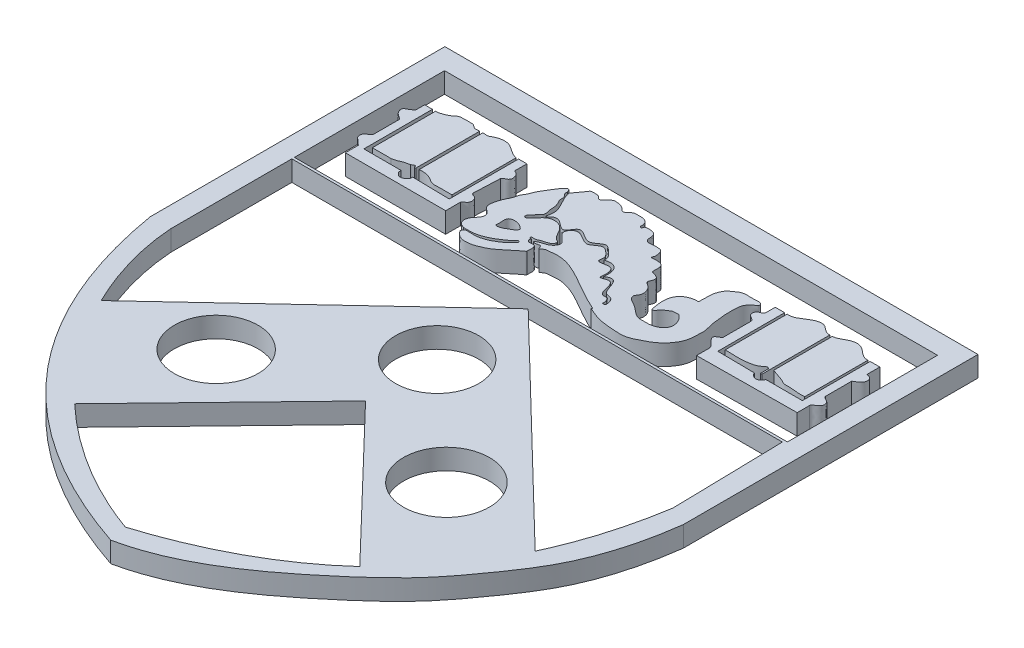
from build123d import *

# Parameters (mm, degrees)
SKETCH1_W           = 3061.588364983
SKETCH1_H           = 932.344777089
SKETCH1_R           = 260.223780603
SKETCH1_R_2         = 267.078180011
BOSS_EXTRUDE2_DEPTH = 127


with BuildPart() as part:
    # Sketch1 → Boss-Extrude2 (new body)
    with BuildSketch(Plane(origin=(0, 0, 0), x_dir=(1, 0, 0), z_dir=(0, 1, 0))):
        with BuildLine():
            add(Edge.make_bspline(
                [(4045.993063216, 2199.215225122), (4019.036003243, 1992.157900968), (3940.605770869, 1686.040008177), (3715.627358016, 1353.378287437), (3523.915777169, 1090.685545744), (3098.522374745, 703.752554607), (2693.684229103, 409.014184571), (2351.364587114, 337.566308676)],
                knots=[0, 0, 0, 0, 0.238562273, 0.347750957, 0.454000193, 0.606190934, 1, 1, 1, 1], degree=3))
            add(Edge.make_bspline(
                [(735.025873478, 2199.215225122), (970.843316792, 803.845705557), (2351.364587114, 337.566308676)],
                knots=[0, 0, 0, 1, 1, 1], degree=2))
            Line((735.025873478, 2199.215225122), (735.025873478, 4029.300547421))
            Line((735.025873478, 4029.300547421), (4045.993063216, 4029.300547421))
            Line((4045.993063216, 4029.300547421), (4045.993063216, 2199.215225122))
        make_face()
        with Locations((2394.042717303, 3432.829498618)):
            Rectangle(SKETCH1_W, SKETCH1_H, mode=Mode.SUBTRACT)
        with BuildLine():
            Line((3909.808358994, 2950.727967066), (3924.836899794, 2257.848334291))
            add(Edge.make_bspline(
                [(3924.836899794, 2257.848334291), (3711.113699994, 888.592759576), (2327.24082473, 452.829096435)],
                knots=[0, 0, 0, 1, 1, 1], degree=2))
            add(Edge.make_bspline(
                [(863.248534811, 2199.215225122), (877.47311589, 1989.403129671), (1118.77528022, 1216.127855732), (1775.94718937, 650.753368868), (2327.24082473, 452.829096435)],
                knots=[0, 0, 0, 0, 0.263514086, 1, 1, 1, 1], degree=3))
            Line((863.248534811, 2199.215225122), (863.248534811, 2950.727967066))
            Line((863.248534811, 2950.727967066), (3909.808358994, 2950.727967066))
        make_face(mode=Mode.SUBTRACT)
        with BuildLine():
            Line((2404.114497235, 2877.689743143), (1645.968612036, 2168.886509302))
            Line((1645.968612036, 2168.886509302), (2186.700620039, 2168.886509302))
            ThreePointArc((2186.700620039, 2168.886509302), (2313.474933953, 2567.530457451), (2652.412370001, 2322.356766959))
            ThreePointArc((2652.412370001, 2322.356766959), (2639.442955818, 2241.562435586), (2601.837910613, 2168.886509302))
            Line((2601.837910613, 2168.886509302), (3136.833426647, 2168.886509302))
            Line((3136.833426647, 2168.886509302), (2404.114497235, 2877.689743143))
        make_face()
        with BuildLine():
            Line((2186.700620039, 2168.886509302), (1645.968612036, 2168.886509302))
            Line((1645.968612036, 2168.886509302), (1033.524013592, 1596.301838725))
            add(Edge.make_bspline(
                [(1033.524013592, 1596.301838725), (1150.062361647, 1357.675014985), (1312.473356702, 1141.98075495), (1506.241949749, 958.912307426)],
                knots=[0.263514086, 0.263514086, 0.263514086, 0.263514086, 0.595636539, 0.595636539, 0.595636539, 0.595636539], degree=3))
            Line((1506.241949749, 958.912307426), (2394.269265326, 1877.454297427))
            Line((2394.269265326, 1877.454297427), (3267.142356524, 968.732165323))
            add(Edge.make_bspline(
                [(3728.737648851, 1596.301838725), (3559.118809212, 1233.711347288), (3267.142356524, 968.732165323)],
                knots=[0.265622113, 0.265622113, 0.265622113, 0.588988437, 0.588988437, 0.588988437], degree=2))
            Line((3728.737648851, 1596.301838725), (3136.833426647, 2168.886509302))
            Line((3136.833426647, 2168.886509302), (2601.837910613, 2168.886509302))
            ThreePointArc((2601.837910613, 2168.886509302), (2394.269265326, 2064.213662283), (2186.700620039, 2168.886509302))
        make_face()
        with Locations(Location((1653.259196935, 1690.93559152, 0), (0, 0, 270))):
            Circle(SKETCH1_R, mode=Mode.SUBTRACT)
        with Locations(Location((3083.04559979, 1690.93559152, 0), (0, 0, 270))):
            Circle(SKETCH1_R_2, mode=Mode.SUBTRACT)
        with BuildLine():
            add(Edge.make_bspline(
                [(2464.767037316, 3284.870494025), (2543.269819358, 3341.768334078), (2526.919244732, 3193.473978396), (2612.69470791, 3199.983108021), (2625.607421376, 3156.65465207), (2620.730937479, 3137.98419013)],
                knots=[0, 0, 0, 0, 0.586831291, 0.719707818, 1, 1, 1, 1], degree=3))
            Line((2620.730937479, 3137.98419013), (2603.084025454, 3137.98419013))
            add(Edge.make_bspline(
                [(2603.084025454, 3137.98419013), (2609.612915472, 3150.722889915), (2597.711627537, 3187.908577019), (2568.546530941, 3179.846963067), (2547.38089144, 3190.770216808), (2535.676967272, 3228.999651837), (2522.459617855, 3303.454171268), (2448.497240118, 3255.395384405), (2463.30640085, 3315.38994872), (2444.909493012, 3379.138282268), (2350.191254901, 3331.98123862), (2371.208442004, 3394.734318229), (2346.766229124, 3416.999233592), (2328.006165043, 3435.728370679), (2287.089575919, 3452.388606795), (2251.696858141, 3397.516196965), (2191.67790777, 3424.764262901), (2139.677802732, 3466.629554465), (2071.918788719, 3382.581092791), (2180.649082031, 3344.723562591), (2124.9486931, 3275.894794605), (2090.931864057, 3278.678610454), (2052.319167749, 3255.11213609), (2082.496059895, 3248.382490532), (2106.981578747, 3265.539443736), (2111.793633986, 3226.444059126), (2132.168593174, 3250.482111261), (2160.890726759, 3252.525076834), (2234.242378581, 3263.735226313), (2331.312183488, 3228.164699449), (2457.476715616, 3154.525364868), (2543.902080581, 3105.811460397), (2603.084025454, 3080.266973626)],
                knots=[0, 0, 0, 0, 0.032556061, 0.042948581, 0.052816971, 0.074630225, 0.120721843, 0.149452151, 0.169593618, 0.20705935, 0.251664852, 0.273960648, 0.296134008, 0.310450952, 0.325903722, 0.373059412, 0.395061266, 0.443790315, 0.47819684, 0.537519426, 0.563826413, 0.609542575, 0.616869593, 0.626603883, 0.647836981, 0.659655735, 0.672273917, 0.686951174, 0.717994813, 0.810907321, 0.876411443, 1, 1, 1, 1], degree=3))
            Line((2603.084025454, 3080.266973626), (2597.584863407, 3074.357913841))
            add(Edge.make_bspline(
                [(2597.584863407, 3074.357913841), (2608.974774561, 3069.30998213), (2640.046426606, 3055.873255387), (2696.027097611, 3036.672943159), (2772.670796603, 3029.996634607), (2847.16209479, 3023.308453093), (2900.977740862, 3046.786714057), (2929.248617867, 3062.480285098), (2968.754766282, 3081.123305601), (3026.625382521, 3124.356350293), (3068.67799265, 3196.784483692), (3068.994778868, 3264.835928169), (3074.355578085, 3310.562172072), (3058.175469267, 3353.800679368), (3053.642682679, 3393.48506246), (3049.536185981, 3426.151228403), (3047.176742493, 3452.814430142), (3045.42211855, 3477.270934381), (3046.249419033, 3498.95354119), (3047.065911211, 3526.077302814), (3047.695874264, 3554.619830796), (3064.38849516, 3580.725911522), (3082.573392728, 3599.530389383), (3104.498218826, 3606.22920432), (3103.097927236, 3626.464875974), (3080.65916707, 3635.768995416), (3054.661529994, 3629.29127928), (3019.449991823, 3631.251519654), (2991.275831749, 3631.903001573), (2964.713993883, 3620.634339325), (2946.882730267, 3605.947753608), (2922.300093096, 3590.971835009), (2908.920650715, 3565.965198211), (2898.426604665, 3539.288479415), (2896.719700125, 3514.955262525), (2896.163769466, 3485.394779706), (2893.629113567, 3466.229041479), (2896.746141536, 3442.596552121), (2881.966496535, 3445.855646122), (2867.913221451, 3444.031493119), (2847.545898595, 3439.266391985), (2825.52478124, 3429.843576895), (2801.438802673, 3411.474335417), (2782.612681095, 3377.027995909), (2777.901028676, 3327.657099719), (2784.537979988, 3294.556874466), (2790.536912617, 3247.567032361), (2812.921485506, 3270.268399927), (2822.99244638, 3284.915077594), (2839.142701291, 3297.482786031), (2851.632618396, 3304.568392773), (2864.418179087, 3313.802518999), (2881.071222263, 3313.723900775), (2903.314305468, 3317.480691503), (2918.608642284, 3301.386492021), (2940.386914172, 3274.192655642), (2954.33909077, 3219.551324075), (2894.999234337, 3167.976606658), (2837.828061905, 3169.140739084), (2784.699634964, 3170.633510758), (2748.91496638, 3198.292275263), (2710.938142866, 3231.684779821), (2670.031839253, 3246.73176231), (2663.113584001, 3263.851992945)],
                knots=[0.192850773, 0.192850773, 0.192850773, 0.192850773, 0.200326028, 0.213178327, 0.228039709, 0.246584143, 0.256741091, 0.262628514, 0.266030917, 0.282912316, 0.305525509, 0.312434736, 0.323658699, 0.332590135, 0.339619576, 0.347580918, 0.352343802, 0.355673279, 0.362282425, 0.365318683, 0.372005823, 0.379021887, 0.383081295, 0.388018719, 0.390335965, 0.39319185, 0.400958714, 0.406206298, 0.414340744, 0.417445142, 0.423283619, 0.428178801, 0.434404861, 0.439757248, 0.445316962, 0.448955812, 0.457208378, 0.458538805, 0.460712029, 0.463583766, 0.468045833, 0.472775597, 0.478007306, 0.485838641, 0.495786929, 0.505718817, 0.510762475, 0.514860474, 0.519077374, 0.522757832, 0.526657269, 0.527821209, 0.532088366, 0.53628665, 0.540515399, 0.544209276, 0.557818426, 0.568272004, 0.58612177, 0.590945066, 0.599687152, 0.61176102, 0.622578416, 0.622578416, 0.622578416, 0.622578416], degree=3))
            Line((2663.113584001, 3263.851992945), (2649.716964234, 3269.100201106))
            add(Edge.make_bspline(
                [(1929.963277011, 3569.644406702), (2365.286728969, 3792.7011874), (2649.716964234, 3269.100201106)],
                knots=[0, 0, 0, 1, 1, 1], degree=2))
            add(Edge.make_bspline(
                [(1929.963277011, 3569.644406702), (1952.014849921, 3528.268958704), (1979.300128061, 3488.381640917), (1959.428632751, 3434.367141661)],
                knots=[0.312671837, 0.312671837, 0.312671837, 0.312671837, 1, 1, 1, 1], degree=3))
            add(Edge.make_bspline(
                [(1959.428632751, 3434.367141661), (1967.259945647, 3426.67287531), (1980.261160084, 3448.879868834), (2030.59764576, 3463.628039217), (2090.429970884, 3373.674116364), (2135.512386846, 3508.376641384), (2228.700772585, 3384.524022341), (2294.545966584, 3482.656318698), (2350.932801628, 3429.531715851), (2382.353956214, 3404.951204328), (2376.728260476, 3376.260880501)],
                knots=[0, 0, 0, 0, 0.046896544, 0.113659028, 0.283898439, 0.409478672, 0.615730634, 0.76876615, 0.854488682, 1, 1, 1, 1], degree=3))
            add(Edge.make_bspline(
                [(2376.728260476, 3376.260880501), (2476.11541457, 3403.732739848), (2464.767037316, 3284.870494025)],
                knots=[0, 0, 0, 1, 1, 1], degree=2))
        make_face()
        with BuildLine():
            Line((2649.716964234, 3269.100201106), (2663.113584001, 3263.851992945))
            add(Edge.make_bspline(
                [(2663.113584001, 3263.851992945), (2661.314435892, 3268.304247084), (2659.437249368, 3278.337001283), (2669.467146029, 3289.603595943), (2678.438220618, 3306.94775862), (2679.993551581, 3331.89372017), (2667.460694632, 3359.288710159), (2649.386150598, 3376.901843711), (2630.680633081, 3386.391793642), (2628.102302849, 3401.757956908), (2637.963018996, 3416.083844994), (2641.079015906, 3441.473661656), (2620.630878092, 3453.025182425), (2606.804304375, 3458.793296074), (2589.997419032, 3459.323866855), (2587.851356068, 3484.752388195), (2592.370892236, 3505.383717874), (2582.151889227, 3526.432706376), (2565.962616412, 3535.85975865), (2544.534926688, 3536.713052368), (2528.02722003, 3538.339122119), (2505.81373652, 3533.921120885), (2518.188383093, 3557.15644223), (2512.634748374, 3572.652137825), (2511.325623212, 3592.887904674), (2498.575799957, 3607.652126226), (2474.678638199, 3609.705870773), (2447.432526563, 3610.577618027), (2418.128501654, 3603.668683746), (2398.972821668, 3622.499359043), (2401.731956085, 3645.406742795), (2393.351314984, 3673.979689604), (2365.337019011, 3682.387560051), (2344.158358739, 3682.794821411), (2321.97305899, 3679.962162555), (2323.807955354, 3662.352448063), (2310.92139946, 3664.770698828), (2308.228819505, 3673.951791703), (2309.686400777, 3683.972658839), (2306.493392336, 3697.306926911), (2298.598922716, 3711.993952013), (2283.245228429, 3719.133141224), (2266.969826322, 3723.72509874), (2248.585740392, 3721.919473017), (2230.853250535, 3722.987495794), (2215.081205031, 3721.417475261), (2204.316988095, 3713.34867902), (2194.355795639, 3706.462646602), (2185.95587467, 3694.705700891), (2167.584783872, 3693.577371457), (2156.716434401, 3708.515258083), (2142.511715712, 3718.493990965), (2125.320734422, 3725.671001327), (2106.792531652, 3725.433533612), (2089.062106511, 3729.158572588), (2075.678923082, 3718.310047357), (2059.772481578, 3707.858701922), (2050.636547518, 3687.558945865), (2029.140273862, 3685.341279051), (2022.092642363, 3699.762405994), (2007.02440534, 3706.513261807), (1990.544053456, 3706.088419403), (1976.750975108, 3706.881358423), (1965.0026361, 3705.008345715), (1957.205586106, 3694.639541928), (1949.152796939, 3680.877949586), (1932.780561207, 3661.896852963), (1921.604603977, 3643.807082717), (1913.046506608, 3631.810979489), (1909.573828675, 3629.344843141), (1908.050154284, 3628.504505843)],
                knots=[0.622578416, 0.622578416, 0.622578416, 0.622578416, 0.625391567, 0.628080948, 0.631118685, 0.637125295, 0.642228955, 0.648660331, 0.652411922, 0.653528867, 0.657540285, 0.662535819, 0.666454215, 0.670152397, 0.671995358, 0.67544046, 0.682233887, 0.685631317, 0.688460097, 0.693110559, 0.697807721, 0.700006392, 0.703062236, 0.708060927, 0.710804166, 0.714912606, 0.718382117, 0.724678312, 0.731927867, 0.734148812, 0.739638938, 0.744834377, 0.750590058, 0.755018119, 0.758916367, 0.760857028, 0.762734925, 0.764140702, 0.766243327, 0.768768016, 0.772249211, 0.775800013, 0.778528129, 0.782352131, 0.786682252, 0.789307634, 0.791554106, 0.794591531, 0.796578746, 0.799964401, 0.803593867, 0.807013434, 0.810397308, 0.814481912, 0.818257532, 0.820351551, 0.824402319, 0.829740311, 0.832472748, 0.835088191, 0.838358596, 0.841821403, 0.844874032, 0.846783204, 0.848544114, 0.852307293, 0.856483028, 0.863520807, 0.864774956, 0.865665049, 0.865665049, 0.865665049, 0.865665049], degree=3))
            add(Edge.make_bspline(
                [(1908.050154284, 3628.504505843), (1910.983429542, 3607.596499477), (1919.931815804, 3588.466474553), (1929.963277011, 3569.644406702)],
                knots=[0, 0, 0, 0, 0.312671837, 0.312671837, 0.312671837, 0.312671837], degree=3))
            add(Edge.make_bspline(
                [(1929.963277011, 3569.644406702), (2365.286728969, 3792.7011874), (2649.716964234, 3269.100201106)],
                knots=[0, 0, 0, 1, 1, 1], degree=2))
        make_face()
        with BuildLine():
            add(Edge.make_bspline(
                [(1773.99549811, 3084.398154876), (1775.594431531, 3081.748510418), (1783.880032077, 3070.091590704), (1799.078082721, 3056.07809208), (1831.663674296, 3042.349203232), (1860.093885791, 3044.878225576), (1890.039180943, 3050.267918379), (1911.650669491, 3058.608568849), (1984.00988121, 3087.281905523), (2032.290751031, 3142.419292102), (2087.975045788, 3179.913364778), (2090.429761997, 3184.399591279)],
                knots=[0.003789591, 0.003789591, 0.003789591, 0.003789591, 0.00565559, 0.012389798, 0.015797809, 0.026635126, 0.028667046, 0.03407684, 0.040466151, 0.075054585, 0.078282267, 0.078282267, 0.078282267, 0.078282267], degree=3))
            add(Edge.make_bspline(
                [(1898.554586681, 3627.001422707), (1889.38060856, 3608.103859064), (1917.597156624, 3598.037221519), (1916.091575637, 3574.957812313), (1915.291741954, 3563.222374466), (1921.457645796, 3548.558469769), (1934.500153236, 3527.412618002), (1938.851122963, 3504.586070504), (1937.8033998, 3484.644789518), (1940.756488942, 3473.030120682), (1945.763949514, 3458.769873184), (1944.487760084, 3445.249986555), (1944.556799684, 3433.913820276), (1938.42824419, 3428.739904377), (1931.783079285, 3423.475434565), (1924.005983131, 3414.236893144), (1917.458773938, 3400.088935471), (1904.629885016, 3390.060108128), (1895.13021172, 3379.349396666), (1892.219558835, 3362.08188531), (1909.213110383, 3359.505842189), (1918.624478497, 3369.33480997), (1931.636906007, 3380.139003226), (1944.148232564, 3396.487205793), (1960.150534772, 3415.00675922), (1980.621466748, 3431.104413238), (2009.791722559, 3435.807080141), (2039.692647368, 3432.135347274), (2070.436203583, 3411.325238565), (2091.102033199, 3376.089462704), (2108.111179598, 3342.126785488), (2138.700355972, 3329.812142341), (2134.991372681, 3311.075785802), (2122.492741531, 3298.389563815), (2102.687784377, 3291.003714794), (2072.539991473, 3285.733465754), (2053.318467334, 3268.713418963), (2024.666307547, 3278.484315629), (2027.770663536, 3260.825706355), (2040.985202279, 3266.247215705), (2030.683693003, 3251.53198696), (2045.072108074, 3234.733829245), (2064.7964562, 3241.628545398), (2086.74787946, 3238.307455002), (2092.844631378, 3212.289172135), (2089.204873459, 3196.485666127), (2090.429761997, 3184.399591279)],
                knots=[0, 0, 0, 0, 0.055654997, 0.063679332, 0.077751865, 0.095904148, 0.116878381, 0.163693439, 0.17230359, 0.185424146, 0.204637683, 0.223398045, 0.232509938, 0.241508714, 0.249140856, 0.262152688, 0.282474299, 0.302047336, 0.316579662, 0.333553046, 0.347506169, 0.361341168, 0.378962296, 0.406093804, 0.431577025, 0.463686413, 0.492891884, 0.530956126, 0.564787911, 0.61647831, 0.669611268, 0.694524273, 0.712220058, 0.723965263, 0.755621342, 0.782577775, 0.827890661, 0.84317039, 0.854771021, 0.863117951, 0.871846739, 0.893465526, 0.919753707, 0.939987678, 0.960256912, 1, 1, 1, 1], degree=3))
            add(Edge.make_bspline(
                [(1898.554586681, 3627.001422707), (1895.955798602, 3628.495439421), (1894.37010751, 3638.180993805), (1885.015130658, 3652.496177315), (1868.314593212, 3636.821636988), (1846.732987679, 3614.604807613), (1826.583227717, 3570.403211311), (1796.81015178, 3532.668764714), (1788.312005552, 3499.313273324), (1777.059999052, 3480.445625334), (1761.419152259, 3456.398928444), (1759.259406604, 3427.992356959), (1741.886942909, 3398.412020814), (1732.883711248, 3375.150847337), (1724.547819254, 3345.089345246), (1719.966646915, 3321.990483451), (1724.531174946, 3300.053616518), (1733.454961189, 3286.373767318), (1747.647912743, 3278.714196798), (1759.284953627, 3268.96954517), (1767.011999129, 3255.868931419), (1768.753746046, 3239.507040919), (1761.253363005, 3221.289896242), (1745.664990263, 3203.777486493), (1728.318570853, 3180.961799215), (1722.996628404, 3149.877011071), (1736.437514094, 3127.667125705), (1751.3611624, 3119.344193707), (1761.77567159, 3117.777428893), (1764.341643819, 3114.652068486)],
                knots=[0.867645066, 0.867645066, 0.867645066, 0.867645066, 0.869872345, 0.872557095, 0.875941044, 0.880285969, 0.892776985, 0.90362181, 0.908934181, 0.91310028, 0.916759684, 0.926012917, 0.929360397, 0.937236388, 0.940870006, 0.948141561, 0.950990265, 0.954137979, 0.957552212, 0.960531732, 0.963142666, 0.966489032, 0.969985937, 0.974607696, 0.980518496, 0.987045004, 0.992161658, 0.994749026, 0.997477608, 0.997477608, 0.997477608, 0.997477608], degree=3))
            add(Edge.make_bspline(
                [(1764.341643819, 3114.652068486), (1774.758651296, 3114.51244457), (1790.731801224, 3114.879596129), (1812.994629299, 3114.279713884), (1833.984673376, 3116.551854754), (1859.134072168, 3122.35036058), (1888.466167107, 3132.584040201), (1919.293954195, 3148.308288659), (1949.819529097, 3167.424240042), (1976.320888125, 3185.916065352), (1992.598304713, 3200.332723152), (1998.882706805, 3211.340564833), (2005.286254545, 3213.093208702), (2011.924775062, 3214.960309562), (2015.454004347, 3208.089777135), (2015.491784039, 3200.980165202), (2009.05052182, 3194.805363828), (2002.512853729, 3188.210025642), (1985.159029706, 3172.021771736), (1964.944967519, 3153.395532994), (1937.111715375, 3137.857815768), (1915.460023477, 3124.896199781), (1891.327149943, 3116.786241251), (1866.538873874, 3108.38103048), (1833.927469457, 3106.675833937), (1807.657835369, 3106.788492367), (1782.190044517, 3108.741136122), (1776.750426792, 3097.483926795), (1771.305366643, 3089.148719235), (1773.809968642, 3084.707650547)],
                knots=[0, 0, 0, 0, 0.054416946, 0.083521304, 0.116256377, 0.164416791, 0.218114949, 0.27818627, 0.344753145, 0.406484691, 0.446166985, 0.459403006, 0.468414198, 0.481036219, 0.488833912, 0.504336592, 0.514961118, 0.533716733, 0.553539365, 0.638661623, 0.676227808, 0.71984114, 0.770141158, 0.808714513, 0.856476611, 0.9368855, 0.958327214, 0.972460643, 0.999371445, 0.999371445, 0.999371445, 0.999371445], degree=3))
            add(Edge.make_bspline(
                [(1773.809968642, 3084.707650547), (1773.87150849, 3084.604301679), (1773.933353142, 3084.501137319), (1773.99549811, 3084.398154876)],
                knots=[0.003717066, 0.003717066, 0.003717066, 0.003717066, 0.003789591, 0.003789591, 0.003789591, 0.003789591], degree=3))
        make_face()
        with BuildLine():
            add(Edge.make_bspline(
                [(1852.354693182, 3230.474720809), (1855.883850773, 3221.919385108), (1884.85446101, 3229.127667292), (1904.93577979, 3240.434646412), (1925.523841047, 3252.777138419), (1942.518746178, 3262.817944337), (1953.609988396, 3279.822226414), (1940.663641608, 3291.370988174), (1928.046351828, 3300.361418538), (1908.161645029, 3308.823565193), (1885.349682927, 3311.872354008), (1858.856068083, 3307.529385157), (1850.69841834, 3285.908904378), (1852.703446171, 3266.184536684), (1853.429511549, 3248.363752689), (1851.017401516, 3233.716565027), (1852.354693182, 3230.474720809)],
                knots=[0, 0, 0, 0, 0.118995444, 0.183982217, 0.265854107, 0.354672315, 0.40168796, 0.433406919, 0.512079877, 0.570068513, 0.649854728, 0.754911943, 0.803686888, 0.871499908, 0.954909462, 1, 1, 1, 1], degree=3))
        make_face(mode=Mode.SUBTRACT)
        with BuildLine():
            add(Edge.make_bspline(
                [(3162.721860271, 3504.87715995), (3156.714689992, 3522.143976545), (3118.122894821, 3525.215373171), (3124.567787422, 3582.531773737), (3160.71518194, 3576.901502377), (3162.721860271, 3597.432833971)],
                knots=[0, 0, 0, 0, 0.405153797, 0.647830187, 1, 1, 1, 1], degree=3))
            Line((3162.721860271, 3597.432833971), (3162.721860271, 3653.548707221))
            Line((3162.721860271, 3653.548707221), (3221.009025347, 3653.548707221))
            Line((3221.009025347, 3653.548707221), (3221.009025347, 3238.450323332))
            Line((3221.009025347, 3238.450323332), (3450.837122371, 3235.534442783))
            add(Edge.make_bspline(
                [(3450.837122371, 3235.534442783), (3458.533550286, 3211.388186109), (3490.475852326, 3207.657972466)],
                knots=[0, 0, 0, 1, 1, 1], degree=2))
            add(Edge.make_bspline(
                [(3490.475852326, 3207.657972466), (3504.664014526, 3208.781186914), (3520.00801118, 3220.774824199), (3521.221487492, 3235.534442783)],
                knots=[0, 0, 0, 0, 1, 1, 1, 1], degree=3))
            Line((3521.221487492, 3235.534442783), (3748.997477968, 3235.534442783))
            Line((3748.997477968, 3235.534442783), (3748.997477968, 3656.840380399))
            Line((3748.997477968, 3656.840380399), (3808.709873533, 3656.840380399))
            Line((3808.709873533, 3656.840380399), (3808.709873533, 3575.710004952))
            add(Edge.make_bspline(
                [(3797.58567591, 3493.482041606), (3807.389063467, 3500.862331064), (3827.598085445, 3508.062798412), (3843.952249432, 3530.704693081), (3846.590209619, 3551.882880704), (3833.85575602, 3570.976052845), (3818.181368812, 3575.769291151), (3808.709873533, 3575.710004952)],
                knots=[0, 0, 0, 0, 0.294296835, 0.49004171, 0.636412202, 0.773293652, 1, 1, 1, 1], degree=3))
            Line((3797.58567591, 3493.482041606), (3797.58567591, 3329.885753458))
            add(Edge.make_bspline(
                [(3797.58567591, 3329.885753458), (3798.568742868, 3325.504426203), (3809.674459022, 3315.798201924), (3823.428047845, 3310.971363133), (3831.610146668, 3304.595154396)],
                knots=[0, 0, 0, 0, 0.287593744, 1, 1, 1, 1], degree=3))
            add(Edge.make_bspline(
                [(3797.58567591, 3230.474720809), (3798.075668427, 3242.665323724), (3829.741317484, 3253.398190827), (3848.25198797, 3281.610147495), (3831.610146668, 3304.595154396)],
                knots=[0, 0, 0, 0, 0.341602312, 1, 1, 1, 1], degree=3))
            Line((3797.58567591, 3230.474720809), (3797.58567591, 3154.846572963))
            Line((3797.58567591, 3154.846572963), (3177.819333154, 3149.381018369))
            Line((3177.819333154, 3149.381018369), (3177.819333154, 3230.474720809))
            add(Edge.make_bspline(
                [(3177.819333154, 3230.474720809), (3171.067419633, 3254.208121846), (3146.663344568, 3264.39441485), (3118.216530978, 3310.087424706), (3160.028309037, 3320.230685109), (3162.721860271, 3329.885753458)],
                knots=[0, 0, 0, 0, 0.493605664, 0.660951848, 1, 1, 1, 1], degree=3))
            Line((3162.721860271, 3329.885753458), (3162.721860271, 3504.87715995))
        make_face()
        with BuildLine():
            Line((3481.307865568, 3674.201004316), (3481.307865568, 3310.482462642))
            Line((3481.307865568, 3310.482462642), (3481.307865568, 3252.037740527))
            add(Edge.make_bspline(
                [(3472.297350052, 3252.167942685), (3476.806578756, 3248.71553577), (3481.307865568, 3252.037740527)],
                knots=[0, 0, 0, 1, 1, 1], degree=2))
            Line((3472.297350052, 3252.167942685), (3472.112545677, 3300.822642719))
            add(Edge.make_bspline(
                [(3236.430948183, 3269.100201106), (3285.871297058, 3268.333216474), (3361.89527621, 3260.530319224), (3437.798378746, 3288.142390537), (3461.279082625, 3314.444780864), (3472.112545677, 3300.822642719)],
                knots=[0, 0, 0, 0, 0.63664047, 0.861829055, 1, 1, 1, 1], degree=3))
            Line((3236.430948183, 3269.100201106), (3236.430948183, 3653.548707221))
            add(Edge.make_bspline(
                [(3481.307865568, 3674.201004316), (3450.201276622, 3669.665560136), (3426.887860148, 3714.6601241), (3332.355420673, 3709.918321263), (3290.795903961, 3646.390004558), (3236.430948183, 3653.548707221)],
                knots=[0, 0, 0, 0, 0.31654868, 0.42799832, 1, 1, 1, 1], degree=3))
        make_face()
        with BuildLine():
            Line((3496.71799292, 3674.201004316), (3496.71799292, 3310.482462642))
            add(Edge.make_bspline(
                [(3496.71799292, 3310.482462642), (3524.611499262, 3297.413265131), (3562.867527987, 3291.120115783), (3600.895456226, 3266.93577682), (3653.4024658, 3271.405768492), (3694.152969831, 3258.857782592), (3735.161702727, 3263.851992945)],
                knots=[0, 0, 0, 0, 0.372329003, 0.471817952, 0.523941644, 1, 1, 1, 1], degree=3))
            Line((3735.161702727, 3263.851992945), (3735.161702727, 3656.840380399))
            add(Edge.make_bspline(
                [(3496.71799292, 3674.201004316), (3527.688991162, 3675.414314032), (3563.898614545, 3710.978981181), (3630.110131383, 3717.328771625), (3677.66656907, 3683.020826313), (3705.448467546, 3654.384392293), (3735.161702727, 3656.840380399)],
                knots=[0, 0, 0, 0, 0.343692797, 0.549957857, 0.698808842, 1, 1, 1, 1], degree=3))
        make_face()
        with BuildLine():
            add(Edge.make_bspline(
                [(1237.601609394, 3699.803304176), (1245.556479779, 3698.249733333), (1254.285988641, 3689.311202528), (1273.788274215, 3677.668273869), (1289.036652062, 3684.08982286), (1297.968216569, 3681.733277624)],
                knots=[0, 0, 0, 0, 0.356876679, 0.568619312, 1, 1, 1, 1], degree=3))
            Line((1297.968216569, 3681.733277624), (1297.968216569, 3287.743993475))
            add(Edge.make_bspline(
                [(1297.968216569, 3287.743993475), (1291.697903328, 3282.075003601), (1285.218198011, 3287.56481312), (1287.4313352, 3294.943831434), (1283.874249484, 3297.573492882), (1279.570042027, 3296.814146068), (1274.147278594, 3295.710939501), (1269.775118884, 3289.886721139), (1263.79117869, 3290.380645047), (1262.017120119, 3287.743993475)],
                knots=[0, 0, 0, 0, 0.311088658, 0.387237558, 0.451370916, 0.558854039, 0.666259703, 0.807712846, 1, 1, 1, 1], degree=3))
            add(Edge.make_bspline(
                [(1262.017120119, 3287.743993475), (1256.164219985, 3285.883328134), (1245.910438287, 3282.331476212), (1232.446673098, 3281.980929677), (1222.494569082, 3276.939710835), (1211.901457692, 3273.569863583), (1199.184106893, 3266.788807697), (1184.334491164, 3265.382284453), (1175.524623582, 3259.614326332), (1170.867794582, 3260.410354838)],
                knots=[0, 0, 0, 0, 0.192895821, 0.339053424, 0.412267812, 0.539462781, 0.688167141, 0.858735397, 1, 1, 1, 1], degree=3))
            Line((1170.867794582, 3260.410354838), (1053.545025804, 3260.410354838))
            Line((1053.545025804, 3260.410354838), (1053.545025804, 3267.961298949))
            Line((1053.545025804, 3267.961298949), (1053.545025804, 3653.548707221))
            add(Edge.make_bspline(
                [(1053.545025804, 3653.548707221), (1063.892987838, 3652.090670602), (1081.069564488, 3656.084306088), (1105.345378274, 3665.674013505), (1125.163102983, 3675.06765539), (1140.815110233, 3687.92340508), (1154.282422966, 3698.826812492), (1172.120920588, 3699.94416343), (1199.331196455, 3700.918867984), (1221.68624517, 3699.792808183), (1237.601609394, 3699.803304176)],
                knots=[0, 0, 0, 0, 0.157367024, 0.266054151, 0.401879317, 0.489816804, 0.578729339, 0.658567497, 0.755751935, 1, 1, 1, 1], degree=3))
        make_face()
        with BuildLine():
            add(Edge.make_bspline(
                [(1316.320811097, 3681.733277624), (1324.481476378, 3685.684668438), (1344.210322186, 3676.885995633), (1364.922180964, 3690.367867253), (1384.226662836, 3700.396232436), (1411.461245666, 3707.750621626), (1476.64564138, 3710.998529149), (1514.380292198, 3657.905333352), (1554.070331124, 3653.548707221)],
                knots=[0, 0, 0, 0, 0.103996963, 0.214762636, 0.270842968, 0.362031899, 0.545667683, 1, 1, 1, 1], degree=3))
            Line((1554.070331124, 3653.548707221), (1554.070331124, 3254.388751606))
            add(Edge.make_bspline(
                [(1316.320811097, 3287.743993475), (1340.322215215, 3291.668151708), (1373.363911291, 3287.315910976), (1409.016071763, 3266.279711404), (1435.415842177, 3249.731913669), (1487.584817785, 3258.101614966), (1526.279554533, 3251.929025139), (1554.070331124, 3254.388751606)],
                knots=[0, 0, 0, 0, 0.29947076, 0.382756641, 0.50991643, 0.665981345, 1, 1, 1, 1], degree=3))
            Line((1316.320811097, 3287.743993475), (1316.320811097, 3681.733277624))
        make_face()
        with BuildLine():
            add(Edge.make_bspline(
                [(1265.434071723, 3211.087604233), (1267.634166479, 3208.365935366), (1271.9534476, 3205.122724079), (1276.964301589, 3199.135170047), (1281.617698352, 3194.984212897), (1293.842099781, 3184.834655846), (1320.186920945, 3191.607464378), (1331.066780576, 3206.42900954), (1336.334468162, 3211.937075537)],
                knots=[0, 0, 0, 0, 0.1217952, 0.1871429, 0.27206947, 0.340319561, 0.735441716, 1, 1, 1, 1], degree=3))
            Line((1336.334468162, 3211.937075537), (1336.334468162, 3227.697991174))
            Line((1336.334468162, 3227.697991174), (1568.251881441, 3223.590331737))
            Line((1568.251881441, 3223.590331737), (1568.251881441, 3653.548707221))
            Line((1568.251881441, 3653.548707221), (1619.972829657, 3653.548707221))
            Line((1619.972829657, 3653.548707221), (1619.972829657, 3576.768464291))
            add(Edge.make_bspline(
                [(1619.972829657, 3576.768464291), (1628.981663707, 3574.423491338), (1643.536796708, 3567.240940943), (1652.344811212, 3546.617684831), (1656.708770681, 3527.330033758), (1645.100730154, 3510.423319068), (1629.200347276, 3505.189756859), (1621.859782523, 3497.49918502), (1617.55878809, 3493.482041606)],
                knots=[0, 0, 0, 0, 0.2533726, 0.370433432, 0.575519625, 0.732954653, 0.846760938, 1, 1, 1, 1], degree=3))
            Line((1617.55878809, 3493.482041606), (1610.329626515, 3327.761557203))
            add(Edge.make_bspline(
                [(1610.329626515, 3327.761557203), (1614.443921295, 3317.817804029), (1630.109319095, 3318.100481846), (1650.629416709, 3300.049689278), (1653.325929895, 3262.054078017), (1626.327437452, 3250.921071154), (1619.972829657, 3239.999472169)],
                knots=[0, 0, 0, 0, 0.213853959, 0.368490829, 0.6683608, 1, 1, 1, 1], degree=3))
            Line((1619.972829657, 3239.999472169), (1619.972829657, 3149.381018369))
            Line((1619.972829657, 3149.381018369), (996.818824535, 3149.381018369))
            Line((996.818824535, 3149.381018369), (996.818824535, 3230.474720809))
            add(Edge.make_bspline(
                [(996.818824535, 3230.474720809), (984.445759438, 3239.251710226), (970.904047294, 3255.219703989), (945.340948447, 3274.185177103), (945.010095363, 3303.122601791), (967.883580176, 3319.543276407), (983.624792965, 3327.859556361), (985.139900744, 3339.555975107)],
                knots=[0, 0, 0, 0, 0.311087228, 0.43809694, 0.641301055, 0.787743797, 1, 1, 1, 1], degree=3))
            Line((985.139900744, 3339.555975107), (985.139900744, 3498.042682387))
            add(Edge.make_bspline(
                [(985.139900744, 3498.042682387), (971.848748493, 3511.088510349), (942.539067902, 3519.742637783), (930.724513036, 3567.107538953), (958.134750503, 3577.264388319), (974.196066532, 3589.270583626), (987.08654376, 3597.767217277), (985.139900744, 3605.709544922)],
                knots=[0, 0, 0, 0, 0.365770509, 0.573476192, 0.745550043, 0.85562476, 1, 1, 1, 1], degree=3))
            Line((985.139900744, 3605.709544922), (985.139900744, 3653.548707221))
            Line((985.139900744, 3653.548707221), (1033.524013592, 3653.548707221))
            Line((1033.524013592, 3653.548707221), (1033.524013592, 3227.697991174))
            Line((1033.524013592, 3227.697991174), (1053.545025804, 3227.697991174))
            Line((1053.545025804, 3227.697991174), (1265.434071723, 3227.697991174))
            Line((1265.434071723, 3227.697991174), (1265.434071723, 3211.087604233))
        make_face()
    extrude(amount=BOSS_EXTRUDE2_DEPTH)


solid = part.part
